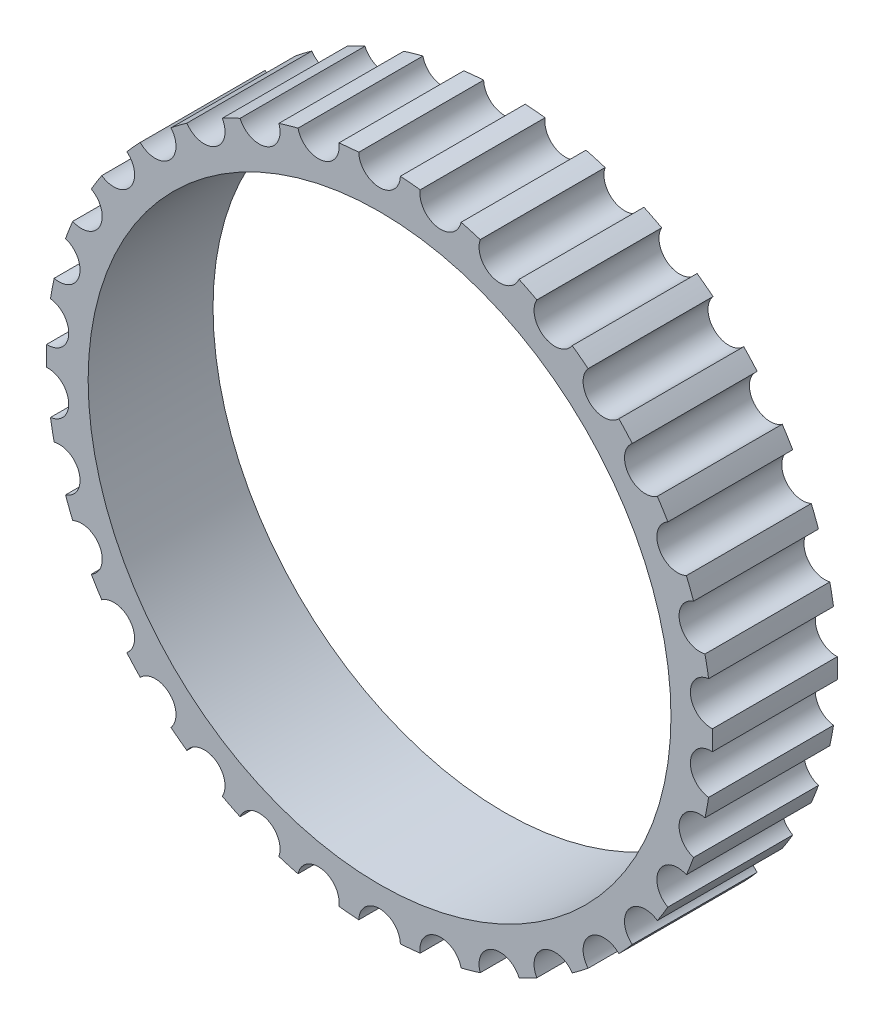
from build123d import *

# Parameters (mm, degrees)
SKETCH1_R           = 7
BOSS_EXTRUDE1_DEPTH = 3


with BuildPart() as part:
    # Sketch1 → Boss-Extrude1 (new body)
    with BuildSketch(Plane.XY):
        with BuildLine():
            ThreePointArc((-0.4997558, 7.984375), (-0.738146876, 7.96587341), (-0.975878549, 7.94025573))
            ThreePointArc((-0.975878549, 7.94025573), (-1.378121384, 7.372298248), (-1.958371564, 7.756595956))
            ThreePointArc((-1.958371564, 7.756595956), (-2.189303921, 7.694605145), (-2.418280524, 7.625740574))
            ThreePointArc((-2.418280524, 7.625740574), (-2.709312496, 6.993541721), (-3.350297333, 7.264675339))
            ThreePointArc((-3.350297333, 7.264675339), (-3.565906846, 7.161306331), (-3.778330856, 7.05153997))
            ThreePointArc((-3.778330856, 7.05153997), (-3.948241222, 6.376628518), (-4.628132745, 6.525364917))
            ThreePointArc((-4.628132745, 6.525364917), (-4.821077091, 6.384137818), (-5.009714662, 6.237207629))
            ThreePointArc((-5.009714662, 6.237207629), (-5.052717327, 5.542566879), (-5.748362647, 5.563841018))
            ThreePointArc((-5.748362647, 5.563841018), (-5.912071338, 5.389565149), (-6.070498644, 5.210474662))
            ThreePointArc((-6.070498644, 5.210474662), (-5.985129205, 4.519759773), (-6.672838954, 4.412847187))
            ThreePointArc((-6.672838954, 4.412847187), (-6.801737086, 4.211457303), (-6.924559076, 4.006305231))
            ThreePointArc((-6.924559076, 4.006305231), (-6.713724685, 3.343037668), (-7.370079733, 3.111579138))
            ThreePointArc((-7.370079733, 3.111579138), (-7.459777835, 2.889933329), (-7.542811953, 2.66570588))
            ThreePointArc((-7.542811953, 2.66570588), (-7.213692324, 2.052472426), (-7.816341286, 1.704349993))
            ThreePointArc((-7.816341286, 1.704349993), (-7.863784797, 1.469996143), (-7.904203416, 1.234329112))
            ThreePointArc((-7.904203416, 1.234329112), (-7.468006322, 0.692012696), (-7.996426712, 0.239081253))
            ThreePointArc((-7.996426712, 0.239081253), (-8, 0), (-7.996426712, -0.239081253))
            ThreePointArc((-7.996426712, -0.239081253), (-7.468006322, -0.692012696), (-7.904203416, -1.234329112))
            ThreePointArc((-7.904203416, -1.234329112), (-7.863784797, -1.469996143), (-7.816341286, -1.704349993))
            ThreePointArc((-7.816341286, -1.704349993), (-7.213692324, -2.052472426), (-7.542811953, -2.66570588))
            ThreePointArc((-7.542811953, -2.66570588), (-7.459777835, -2.889933329), (-7.370079733, -3.111579138))
            ThreePointArc((-7.370079733, -3.111579138), (-6.713724685, -3.343037668), (-6.924559076, -4.006305231))
            ThreePointArc((-6.924559076, -4.006305231), (-6.801737086, -4.211457303), (-6.672838954, -4.412847187))
            ThreePointArc((-6.672838954, -4.412847187), (-5.985129205, -4.519759773), (-6.070498644, -5.210474662))
            ThreePointArc((-6.070498644, -5.210474662), (-5.912071338, -5.389565149), (-5.748362647, -5.563841018))
            ThreePointArc((-5.748362647, -5.563841018), (-5.052717327, -5.542566879), (-5.009714662, -6.237207629))
            ThreePointArc((-5.009714662, -6.237207629), (-4.821077091, -6.384137818), (-4.628132745, -6.525364917))
            ThreePointArc((-4.628132745, -6.525364917), (-3.948241222, -6.376628518), (-3.778330856, -7.05153997))
            ThreePointArc((-3.778330856, -7.05153997), (-3.565906846, -7.161306331), (-3.350297333, -7.264675339))
            ThreePointArc((-3.350297333, -7.264675339), (-2.709312496, -6.993541721), (-2.418280524, -7.625740574))
            ThreePointArc((-2.418280524, -7.625740574), (-2.189303921, -7.694605145), (-1.958371564, -7.756595956))
            ThreePointArc((-1.958371564, -7.756595956), (-1.378121384, -7.372298248), (-0.975878549, -7.94025573))
            ThreePointArc((-0.975878549, -7.94025573), (-0.738146876, -7.96587341), (-0.4997558, -7.984375))
            ThreePointArc((-0.4997558, -7.984375), (0, -7.5), (0.4997558, -7.984375))
            ThreePointArc((0.4997558, -7.984375), (0.738146876, -7.96587341), (0.975878549, -7.94025573))
            ThreePointArc((0.975878549, -7.94025573), (1.378121384, -7.372298248), (1.958371564, -7.756595956))
            ThreePointArc((1.958371564, -7.756595956), (2.189303921, -7.694605145), (2.418280524, -7.625740574))
            ThreePointArc((2.418280524, -7.625740574), (2.709312496, -6.993541721), (3.350297333, -7.264675339))
            ThreePointArc((3.350297333, -7.264675339), (3.565906846, -7.161306331), (3.778330856, -7.05153997))
            ThreePointArc((3.778330856, -7.05153997), (3.948241222, -6.376628518), (4.628132745, -6.525364917))
            ThreePointArc((4.628132745, -6.525364917), (4.821077091, -6.384137818), (5.009714662, -6.237207629))
            ThreePointArc((5.009714662, -6.237207629), (5.052717327, -5.542566879), (5.748362647, -5.563841018))
            ThreePointArc((5.748362647, -5.563841018), (5.912071338, -5.389565149), (6.070498644, -5.210474662))
            ThreePointArc((6.070498644, -5.210474662), (5.985129205, -4.519759773), (6.672838954, -4.412847187))
            ThreePointArc((6.672838954, -4.412847187), (6.801737086, -4.211457303), (6.924559076, -4.006305231))
            ThreePointArc((6.924559076, -4.006305231), (6.713724685, -3.343037668), (7.370079733, -3.111579138))
            ThreePointArc((7.370079733, -3.111579138), (7.459777835, -2.889933329), (7.542811953, -2.66570588))
            ThreePointArc((7.542811953, -2.66570588), (7.213692324, -2.052472426), (7.816341286, -1.704349993))
            ThreePointArc((7.816341286, -1.704349993), (7.863784797, -1.469996143), (7.904203416, -1.234329112))
            ThreePointArc((7.904203416, -1.234329112), (7.468006322, -0.692012696), (7.996426712, -0.239081253))
            ThreePointArc((7.996426712, -0.239081253), (8, 0), (7.996426712, 0.239081253))
            ThreePointArc((7.996426712, 0.239081253), (7.468006322, 0.692012696), (7.904203416, 1.234329112))
            ThreePointArc((7.904203416, 1.234329112), (7.863784797, 1.469996143), (7.816341286, 1.704349993))
            ThreePointArc((7.816341286, 1.704349993), (7.213692324, 2.052472426), (7.542811953, 2.66570588))
            ThreePointArc((7.542811953, 2.66570588), (7.459777835, 2.889933329), (7.370079733, 3.111579138))
            ThreePointArc((7.370079733, 3.111579138), (6.713724685, 3.343037668), (6.924559076, 4.006305231))
            ThreePointArc((6.924559076, 4.006305231), (6.801737086, 4.211457303), (6.672838954, 4.412847187))
            ThreePointArc((6.672838954, 4.412847187), (5.985129205, 4.519759773), (6.070498644, 5.210474662))
            ThreePointArc((6.070498644, 5.210474662), (5.912071338, 5.389565149), (5.748362647, 5.563841018))
            ThreePointArc((5.748362647, 5.563841018), (5.052717327, 5.542566879), (5.009714662, 6.237207629))
            ThreePointArc((5.009714662, 6.237207629), (4.821077091, 6.384137818), (4.628132745, 6.525364917))
            ThreePointArc((4.628132745, 6.525364917), (3.948241222, 6.376628518), (3.778330856, 7.05153997))
            ThreePointArc((3.778330856, 7.05153997), (3.565906846, 7.161306331), (3.350297333, 7.264675339))
            ThreePointArc((3.350297333, 7.264675339), (2.709312496, 6.993541721), (2.418280524, 7.625740574))
            ThreePointArc((2.418280524, 7.625740574), (2.189303921, 7.694605145), (1.958371564, 7.756595956))
            ThreePointArc((1.958371564, 7.756595956), (1.378121384, 7.372298248), (0.975878549, 7.94025573))
            ThreePointArc((0.975878549, 7.94025573), (0.738146876, 7.96587341), (0.4997558, 7.984375))
            ThreePointArc((0.4997558, 7.984375), (0, 7.5), (-0.4997558, 7.984375))
        make_face()
        Circle(SKETCH1_R, mode=Mode.SUBTRACT)
    extrude(amount=BOSS_EXTRUDE1_DEPTH)


solid = part.part
